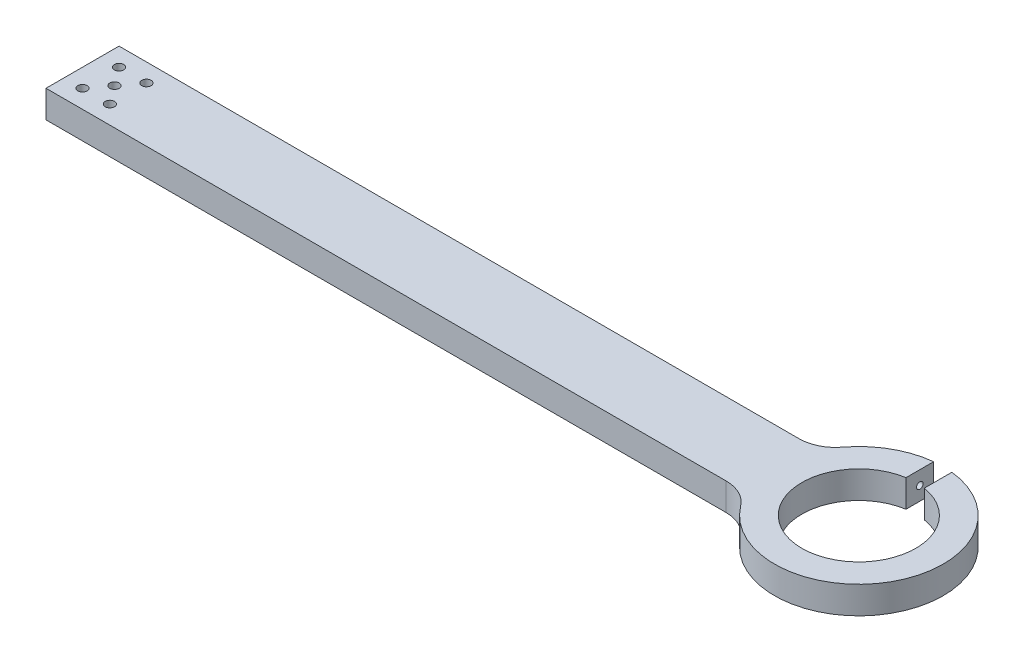
from build123d import *

# Parameters (mm, degrees)
BOSS_EXTRUDE1_DEPTH   = 4.7625
SKETCH8_W             = 1.1303
SKETCH8_H             = 266.825
F_4_40_TAPPED_HOLE2_D = 2.2606
FILLET2_R             = 12.7
CUT_EXTRUDE1_START    = -9.525
SKETCH11_R            = 2.413
CUT_EXTRUDE1_DEPTH    = 17.6497001
F_4_CLEARANCE_HOLE1_D = 3.2639


with BuildPart() as part:
    # Sketch2 → Boss-Extrude1 (new body, symmetric)
    with BuildSketch(Plane(origin=(0, 0, 0), x_dir=(1, 0, 0), z_dir=(0, 1, 0))):
        with BuildLine():
            Line((266.825, 19.568804386), (266.825, 29.177461594))
            ThreePointArc((266.825, 29.177461594), (253.046230135, 23.957766537), (243.54031576, 12.7))
            Line((243.54031576, 12.7), (0, 12.7))
            Line((0, 12.7), (0, -12.7))
            Line((0, -12.7), (243.54031576, -12.7))
            ThreePointArc((243.54031576, -12.7), (293.957766537, -16.953769865), (273.175, 29.177461594))
            Line((273.175, 29.177461594), (273.175, 19.568804386))
            ThreePointArc((273.175, 19.568804386), (270, -19.8247), (266.825, 19.568804386))
        make_face()
    extrude(amount=BOSS_EXTRUDE1_DEPTH, both=True)

    # Sketch8 → #4-40 Tapped Hole1 (revolve, cut)
    with BuildSketch(Plane(origin=(266.825, 0, -24.37313299), x_dir=(0, 0, -1), z_dir=(0, 1, 0))):
        with Locations((0.56515, 133.4125)):
            Rectangle(SKETCH8_W, SKETCH8_H)
    revolve(axis=Axis((273.175, 0, -24.37313299), (-1, 0, 0)), mode=Mode.SUBTRACT)

    # #4-40 Tapped Hole2 (through all)
    with Locations(Plane.ZY.offset(-273.175)):
        with Locations((-24.37313299, 0)):
            Hole(F_4_40_TAPPED_HOLE2_D / 2)

    # Fillet2
    fillet2_edges = [part.edges().sort_by_distance(p)[0] for p in [
        (243.54031576, 0, -12.7),
        (243.54031576, 0, 12.7),
    ]]
    fillet(fillet2_edges, radius=FILLET2_R)

    # Sketch11 → Cut-Extrude1 (cut, through all)
    with BuildSketch(Plane.ZY.offset(-273.175).offset(CUT_EXTRUDE1_START)):
        with Locations((-24.37313299, 0)):
            Circle(SKETCH11_R)
    extrude(amount=-CUT_EXTRUDE1_DEPTH, mode=Mode.SUBTRACT)

    # #4 Clearance Hole1 (through all)
    with Locations(Plane(origin=(0, -4.7625, 0), x_dir=(-1, 0, 0), z_dir=(0, -1, 0))):
        with Locations((-6.35, -6.35), (-15.875, 6.35), (-15.875, -6.35), (-11.1125, 0), (-6.35, 6.35)):
            Hole(F_4_CLEARANCE_HOLE1_D / 2)


solid = part.part
